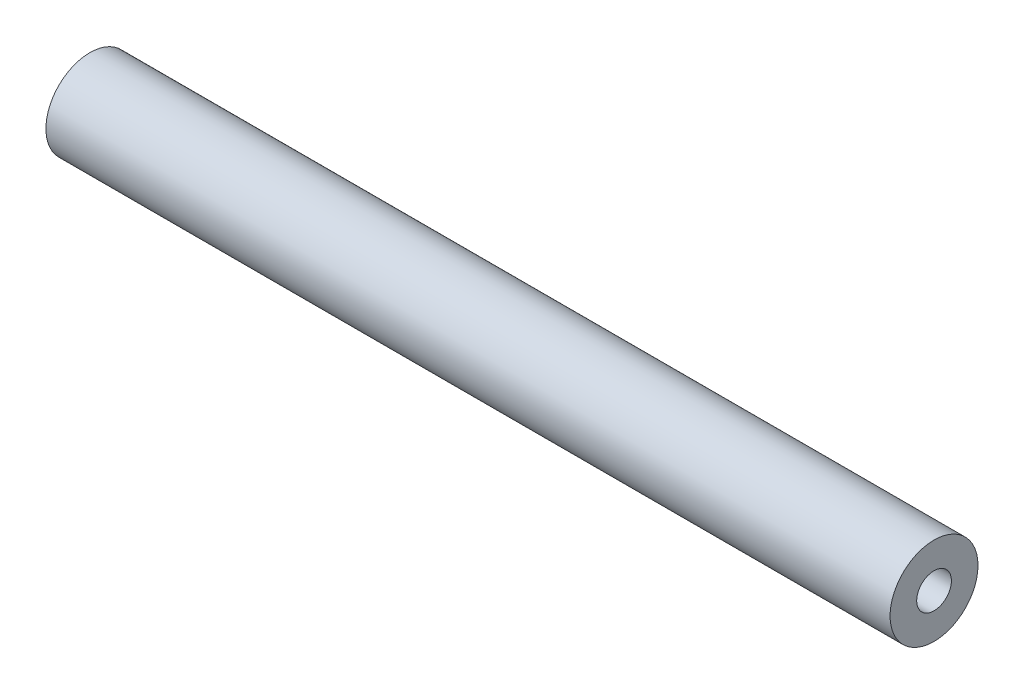
from build123d import *

# Parameters (mm, degrees)
SKETCH1_R           = 24.13
SKETCH1_R_2         = 9.525
BOSS_EXTRUDE1_DEPTH = 231.7115


with BuildPart() as part:
    # Sketch1 → Boss-Extrude1 (new body, symmetric)
    with BuildSketch(Plane(origin=(0, 0, 0), x_dir=(0, 0, -1), z_dir=(1, 0, 0))):
        Circle(SKETCH1_R)
        Circle(SKETCH1_R_2, mode=Mode.SUBTRACT)
    extrude(amount=BOSS_EXTRUDE1_DEPTH, both=True)


solid = part.part
